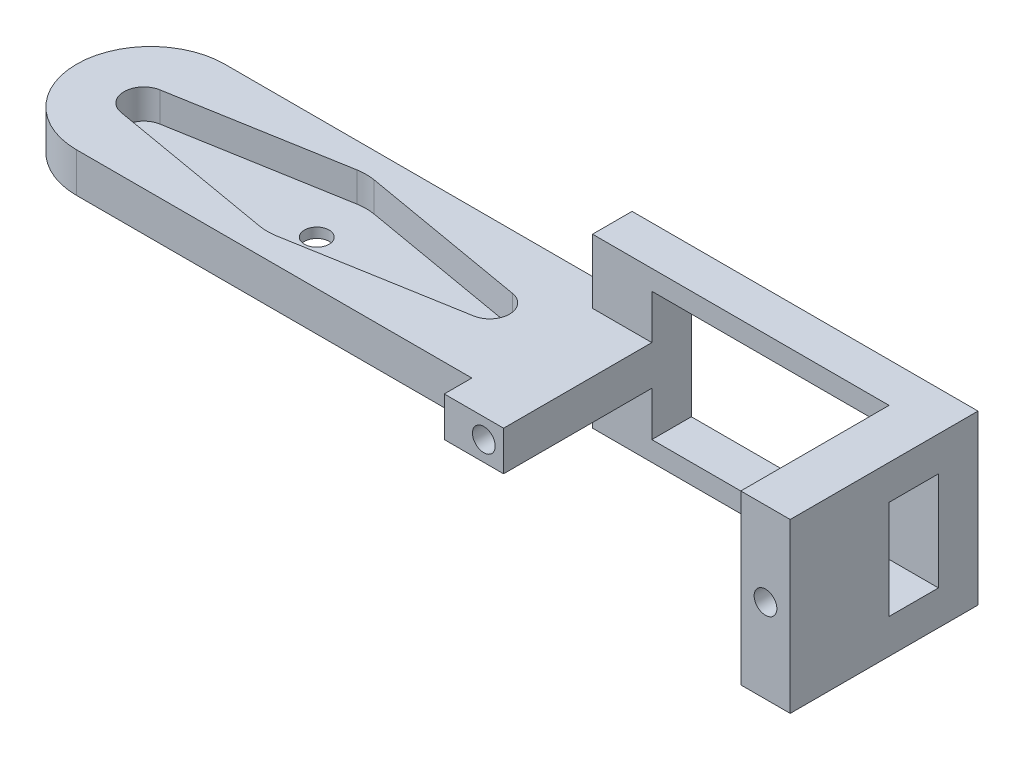
from build123d import *

# Parameters (mm, degrees)
SKETCH_1_W          = 35
SKETCH_1_H          = 17
EXTRUDE_1_DEPTH     = 4
SKETCH_2_W          = 24
SKETCH_2_H          = 13
CUT_EXTRUDE_1_DEPTH = 6
EXTRUDE_2_DEPTH     = 5
SKETCH_5_W          = 4
SKETCH_5_H          = 4
SKETCH_5_R          = 1.15
EXTRUDE_3_DEPTH     = 15
SKETCH_6_R          = 1.15
CUT_EXTRUDE_2_DEPTH = 15
EXTRUDE_5_DEPTH     = 2
EXTRUDE_6_DEPTH     = 4
CUT_EXTRUDE_3_DEPTH = 3
SKETCH_11_R         = 1.25
CUT_EXTRUDE_4_DEPTH = 13.4


with BuildPart() as part:
    # 草圖1 → 填料-伸長1 (new body)
    with BuildSketch(Plane.XY):
        with Locations((-3.721052632, 2.8)):
            Rectangle(SKETCH_1_W, SKETCH_1_H)
    extrude(amount=EXTRUDE_1_DEPTH)

    # 草圖2 → 除料-伸長1 (cut)
    with BuildSketch(Plane.XY):
        with Locations((-3.221052632, 2.8)):
            Rectangle(SKETCH_2_W, SKETCH_2_H)
    extrude(amount=CUT_EXTRUDE_1_DEPTH, mode=Mode.SUBTRACT)

    # 草圖3 → 填料-伸長2 (add)
    with BuildSketch(Plane(origin=(13.778947368, 0, 0), x_dir=(0, 0, -1), z_dir=(1, 0, 0))):
        Polygon((-4, 7.802538439), (-4, 11.3), (-19, 11.3), (-19, -5.694923122), (-4, -5.694923122), (-4, -2.197461561), (-9, -2.197461561), (-9, 7.802538439), align=None)
    extrude(amount=-EXTRUDE_2_DEPTH)

    # 草圖5 → 填料-伸長3 (add)
    with BuildSketch(Plane.XY.offset(4)):
        with Locations((-17.221052632, 2.8)):
            Rectangle(SKETCH_5_W, SKETCH_5_H)
        with Locations((-17.221052632, 2.8)):
            Circle(SKETCH_5_R, mode=Mode.SUBTRACT)
    extrude(amount=EXTRUDE_3_DEPTH)

    # 草圖6 → 除料-伸長2 (cut)
    with BuildSketch(Plane.XY.offset(19)):
        with Locations((11.278947368, 2.802538439)):
            Circle(SKETCH_6_R)
    extrude(amount=-CUT_EXTRUDE_2_DEPTH, mode=Mode.SUBTRACT)

    # 草圖7 → 填料-伸長5 (add)
    with BuildSketch(Plane.ZY.offset(21.221052632)):
        Polygon((4, 4.8), (4, 0.796544916), (19, 0.8), (19, 4.8), align=None)
    extrude(amount=-EXTRUDE_5_DEPTH)

    # 草圖9 → 填料-伸長6 (add)
    with BuildSketch(Plane(origin=(0, 0.8, 0), x_dir=(-1, 0, 0), z_dir=(0, -1, 0))):
        with BuildLine():
            Line((21.221052632, -1.209797885), (21.221052632, -16.209797885))
            Line((21.221052632, -16.209797885), (61.221052632, -16.209797885))
            ThreePointArc((61.221052632, -16.209797885), (68.721052632, -8.709797885), (61.221052632, -1.209797885))
            Line((61.221052632, -1.209797885), (21.221052632, -1.209797885))
        make_face()
    extrude(amount=-EXTRUDE_6_DEPTH)

    # 草圖10 → 除料-伸長3 (cut)
    with BuildSketch(Plane(origin=(0, 4.8, 0), x_dir=(1, 0, 0), z_dir=(0, 1, 0))):
        with BuildLine():
            Line((-45.267861932, -3.783815128), (-62.253576218, -6.739404782))
            ThreePointArc((-62.253576218, -6.739404782), (-63.910719075, -8.709797885), (-62.253576218, -10.680190988))
            Line((-62.253576218, -10.680190988), (-45.267861932, -13.635780642))
            ThreePointArc((-45.267861932, -13.635780642), (-44.410719075, -13.709797885), (-43.553576218, -13.635780642))
            Line((-43.553576218, -13.635780642), (-26.567861932, -10.680190988))
            ThreePointArc((-26.567861932, -10.680190988), (-24.910719075, -8.709797885), (-26.567861932, -6.739404782))
            Line((-26.567861932, -6.739404782), (-43.553576218, -3.783815128))
            ThreePointArc((-43.553576218, -3.783815128), (-44.410719075, -3.709797885), (-45.267861932, -3.783815128))
        make_face()
    extrude(amount=-CUT_EXTRUDE_3_DEPTH, mode=Mode.SUBTRACT)

    # 草圖11 → 除料-伸長4 (cut)
    with BuildSketch(Plane(origin=(0, 4.8, 0), x_dir=(1, 0, 0), z_dir=(0, 1, 0))):
        with Locations((-44.410719075, -8.709797885)):
            Circle(SKETCH_11_R)
    extrude(amount=-CUT_EXTRUDE_4_DEPTH, mode=Mode.SUBTRACT)


solid = part.part
